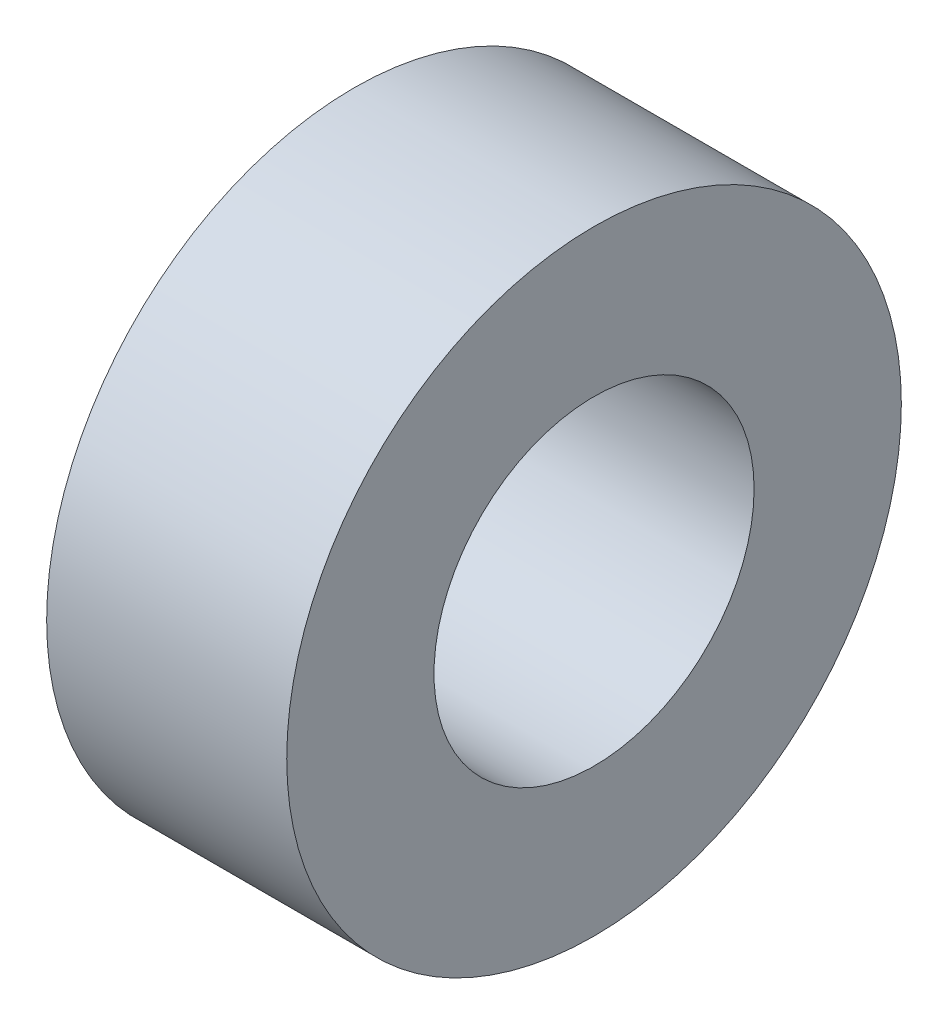
from build123d import *

# Parameters (mm, degrees)
SKETCH1_R           = 6.096
SKETCH1_R_2         = 3.175
BOSS_EXTRUDE1_DEPTH = 4.7625


with BuildPart() as part:
    # Sketch1 → Boss-Extrude1 (new body)
    with BuildSketch(Plane(origin=(0, 0, 0), x_dir=(0, 0, -1), z_dir=(1, 0, 0))):
        Circle(SKETCH1_R)
        Circle(SKETCH1_R_2, mode=Mode.SUBTRACT)
    extrude(amount=BOSS_EXTRUDE1_DEPTH)


solid = part.part
